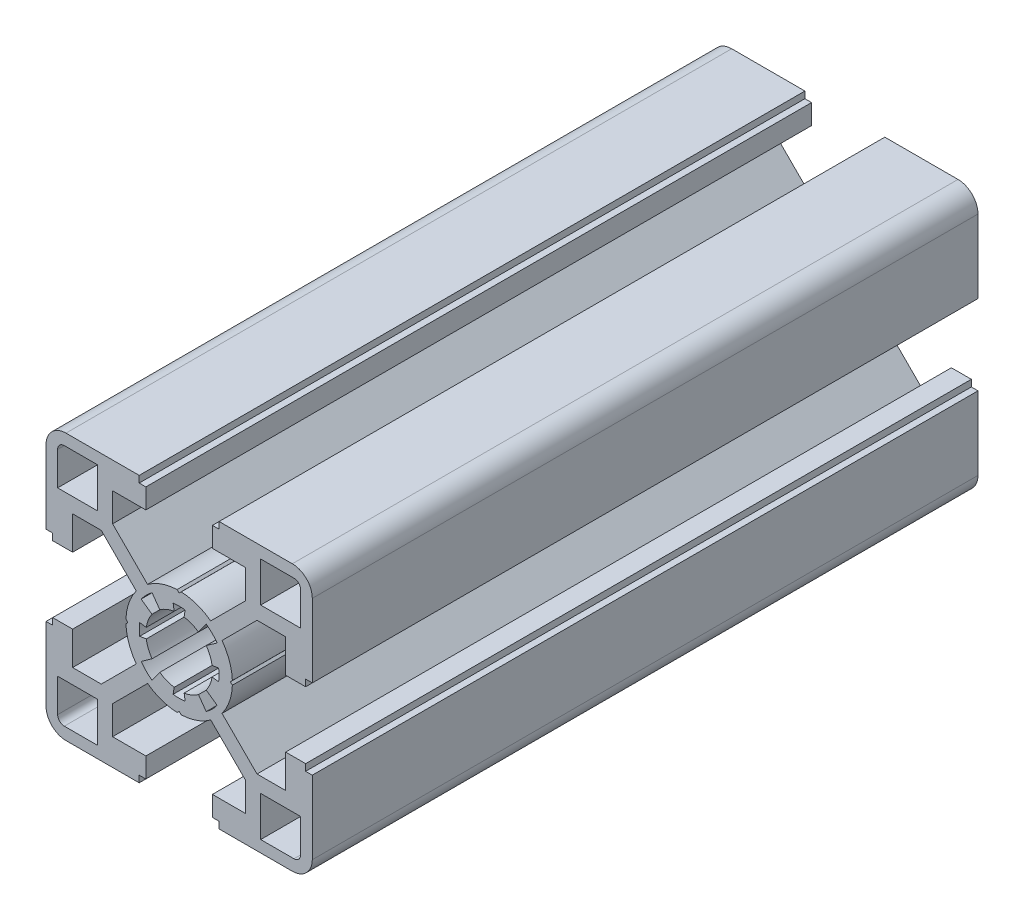
from build123d import *

# Parameters (mm, degrees)
Y_KSEKLIK_EKSTR_ZYON1_DEPTH = 100


with BuildPart() as part:
    # Çizim1 → Yükseklik-Ekstrüzyon1 (new body)
    with BuildSketch(Plane.XY.offset(100)):
        with BuildLine():
            Line((6, -19), (6, -20))
            Line((6, -20), (17, -20))
            ThreePointArc((17, -20), (19.121320344, -19.121320344), (20, -17))
            Line((20, -17), (20, -6))
            Line((20, -6), (19, -6))
            Line((19, -6), (19, -5))
            Line((19, -5), (16.000000001, -5))
            Line((16.000000001, -5), (16.000000001, -10))
            Line((16.000000001, -10), (11.697056277, -10))
            Line((11.697056277, -10), (6.44138072, -4.744324444))
            ThreePointArc((6.44138072, -4.744324444), (7.551143818, -2.642011933), (7.994130058, -0.306405969))
            Line((7.994130058, -0.306405969), (7.7, 0))
            Line((7.7, 0), (7.994130058, 0.306405971))
            ThreePointArc((7.994130058, 0.306405971), (7.551143817, 2.642011934), (6.441380719, 4.744324444))
            Line((6.441380719, 4.744324444), (11.697056275, 10))
            Line((11.697056275, 10), (16.000000001, 10))
            Line((16.000000001, 10), (16.000000001, 5))
            Line((16.000000001, 5), (19, 5))
            Line((19, 5), (19, 6))
            Line((19, 6), (20, 6))
            Line((20, 6), (20, 17))
            ThreePointArc((20, 17), (19.121320344, 19.121320344), (17, 20))
            Line((17, 20), (6, 20))
            Line((6, 20), (6, 19))
            Line((6, 19), (5, 19))
            Line((5, 19), (5, 15.999999999))
            Line((5, 15.999999999), (10.000000001, 15.999999999))
            Line((10.000000001, 15.999999999), (10.000000001, 11.697056275))
            Line((10.000000001, 11.697056275), (4.744324444, 6.441380719))
            ThreePointArc((4.744324444, 6.441380719), (2.642011933, 7.551143817), (0.30640597, 7.994130058))
            Line((0.30640597, 7.994130058), (0, 7.7))
            Line((0, 7.7), (-0.30640597, 7.994130058))
            ThreePointArc((-0.30640597, 7.994130058), (-2.642011933, 7.551143817), (-4.744324444, 6.441380719))
            Line((-4.744324444, 6.441380719), (-9.999999999, 11.697056274))
            Line((-9.999999999, 11.697056274), (-9.999999999, 15.999999999))
            Line((-9.999999999, 15.999999999), (-5, 15.999999999))
            Line((-5, 15.999999999), (-5, 19))
            Line((-5, 19), (-6, 19))
            Line((-6, 19), (-6, 20))
            Line((-6, 20), (-17, 20))
            ThreePointArc((-17, 20), (-19.121320344, 19.121320344), (-20, 17))
            Line((-20, 17), (-20, 6))
            Line((-20, 6), (-19, 6))
            Line((-19, 6), (-19, 5))
            Line((-19, 5), (-15.999999999, 5))
            Line((-15.999999999, 5), (-15.999999999, 10))
            Line((-15.999999999, 10), (-11.697056274, 10))
            Line((-11.697056274, 10), (-6.441380718, 4.744324445))
            ThreePointArc((-6.441380718, 4.744324445), (-7.551143817, 2.642011933), (-7.994130058, 0.306405969))
            Line((-7.994130058, 0.306405969), (-7.699999999, 0))
            Line((-7.699999999, 0), (-7.994130057, -0.306405971))
            ThreePointArc((-7.994130057, -0.306405971), (-7.551143816, -2.642011934), (-6.441380719, -4.744324444))
            Line((-6.441380719, -4.744324444), (-11.697056274, -10))
            Line((-11.697056274, -10), (-15.999999999, -10))
            Line((-15.999999999, -10), (-15.999999999, -5))
            Line((-15.999999999, -5), (-19, -5))
            Line((-19, -5), (-19, -6))
            Line((-19, -6), (-20, -6))
            Line((-20, -6), (-20, -17))
            ThreePointArc((-20, -17), (-19.121320344, -19.121320344), (-17, -20))
            Line((-17, -20), (-6, -20))
            Line((-6, -20), (-6, -19))
            Line((-6, -19), (-5, -19))
            Line((-5, -19), (-5, -16.000000001))
            Line((-5, -16.000000001), (-9.999999999, -16.000000001))
            Line((-9.999999999, -16.000000001), (-9.999999999, -11.697056274))
            Line((-9.999999999, -11.697056274), (-4.744324444, -6.441380719))
            ThreePointArc((-4.744324444, -6.441380719), (-2.642011933, -7.551143817), (-0.306405969, -7.994130058))
            Line((-0.306405969, -7.994130058), (0, -7.7))
            Line((0, -7.7), (0.306405971, -7.994130058))
            ThreePointArc((0.306405971, -7.994130058), (2.642011934, -7.551143817), (4.744324445, -6.441380719))
            Line((4.744324445, -6.441380719), (10.000000001, -11.697056274))
            Line((10.000000001, -11.697056274), (10.000000001, -16.000000001))
            Line((10.000000001, -16.000000001), (5, -16.000000001))
            Line((5, -16.000000001), (5, -19))
            Line((5, -19), (6, -19))
        make_face()
        with BuildLine():
            Line((18.25, 12.25), (12.25, 12.25))
            Line((12.25, 12.25), (12.25, 18.25))
            Line((12.25, 18.25), (17.25, 18.25))
            ThreePointArc((17.25, 18.25), (17.957106781, 17.957106781), (18.25, 17.25))
            Line((18.25, 17.25), (18.25, 12.25))
        make_face(mode=Mode.SUBTRACT)
        with BuildLine():
            Line((-18.25, -12.25), (-12.25, -12.25))
            Line((-12.25, -12.25), (-12.25, -18.25))
            Line((-12.25, -18.25), (-17.25, -18.25))
            ThreePointArc((-17.25, -18.25), (-17.957106781, -17.957106781), (-18.25, -17.25))
            Line((-18.25, -17.25), (-18.25, -12.25))
        make_face(mode=Mode.SUBTRACT)
        with BuildLine():
            Line((-12.25, 18.25), (-12.25, 12.25))
            Line((-12.25, 12.25), (-18.25, 12.25))
            Line((-18.25, 12.25), (-18.25, 17.25))
            ThreePointArc((-18.25, 17.25), (-17.957106781, 17.957106781), (-17.25, 18.25))
            Line((-17.25, 18.25), (-12.25, 18.25))
        make_face(mode=Mode.SUBTRACT)
        with BuildLine():
            Line((12.25, -18.25), (12.25, -12.25))
            Line((12.25, -12.25), (18.25, -12.25))
            Line((18.25, -12.25), (18.25, -17.25))
            ThreePointArc((18.25, -17.25), (17.957106781, -17.957106781), (17.25, -18.25))
            Line((17.25, -18.25), (12.25, -18.25))
        make_face(mode=Mode.SUBTRACT)
        with BuildLine():
            Line((-5.705709703, -4.055228326), (-4.075506937, -2.896591666))
            ThreePointArc((-4.075506937, -2.896591666), (-4.635549588, -1.873947726), (-4.943520622, -0.749402378))
            Line((-4.943520622, -0.749402378), (-5.932224738, -0.899282852))
            ThreePointArc((-5.932224738, -0.899282852), (-6, 0), (-5.932224738, 0.899282853))
            Line((-5.932224738, 0.899282853), (-4.943520622, 0.749402379))
            ThreePointArc((-4.943520622, 0.749402379), (-4.635549588, 1.873947727), (-4.075506937, 2.896591666))
            Line((-4.075506937, 2.896591666), (-5.705709703, 4.055228326))
            ThreePointArc((-5.705709703, 4.055228326), (-4.953610357, 4.945881563), (-4.064132573, 5.699370705))
            Line((-4.064132573, 5.699370705), (-2.902951842, 4.070979081))
            ThreePointArc((-2.902951842, 4.070979081), (-1.877566249, 4.634085136), (-0.749402377, 4.943520623))
            Line((-0.749402377, 4.943520623), (-0.899282852, 5.932224739))
            ThreePointArc((-0.899282852, 5.932224739), (0, 6), (0.899282852, 5.932224739))
            Line((0.899282852, 5.932224739), (0.749402377, 4.943520623))
            ThreePointArc((0.749402377, 4.943520623), (1.87756625, 4.634085136), (2.902951843, 4.07097908))
            Line((2.902951843, 4.07097908), (4.064132575, 5.699370704))
            ThreePointArc((4.064132575, 5.699370704), (4.953610358, 4.945881562), (5.705709704, 4.055228326))
            Line((5.705709704, 4.055228326), (4.075506937, 2.896591666))
            ThreePointArc((4.075506937, 2.896591666), (4.635549589, 1.873947727), (4.943520623, 0.749402378))
            Line((4.943520623, 0.749402378), (5.932224739, 0.899282853))
            ThreePointArc((5.932224739, 0.899282853), (6, 0), (5.932224739, -0.899282853))
            Line((5.932224739, -0.899282853), (4.943520623, -0.749402379))
            ThreePointArc((4.943520623, -0.749402379), (4.635549589, -1.873947727), (4.075506938, -2.896591666))
            Line((4.075506938, -2.896591666), (5.705709704, -4.055228326))
            ThreePointArc((5.705709704, -4.055228326), (4.953610357, -4.945881562), (4.064132573, -5.699370705))
            Line((4.064132573, -5.699370705), (2.902951842, -4.070979081))
            ThreePointArc((2.902951842, -4.070979081), (1.87756625, -4.634085136), (0.749402378, -4.943520623))
            Line((0.749402378, -4.943520623), (0.899282852, -5.932224739))
            ThreePointArc((0.899282852, -5.932224739), (1e-09, -6), (-0.899282851, -5.932224739))
            Line((-0.899282851, -5.932224739), (-0.749402377, -4.943520623))
            ThreePointArc((-0.749402377, -4.943520623), (-1.87756625, -4.634085136), (-2.902951843, -4.07097908))
            Line((-2.902951843, -4.07097908), (-4.064132574, -5.699370704))
            ThreePointArc((-4.064132574, -5.699370704), (-4.953610357, -4.945881562), (-5.705709703, -4.055228326))
        make_face(mode=Mode.SUBTRACT)
    extrude(amount=-Y_KSEKLIK_EKSTR_ZYON1_DEPTH)


solid = part.part
